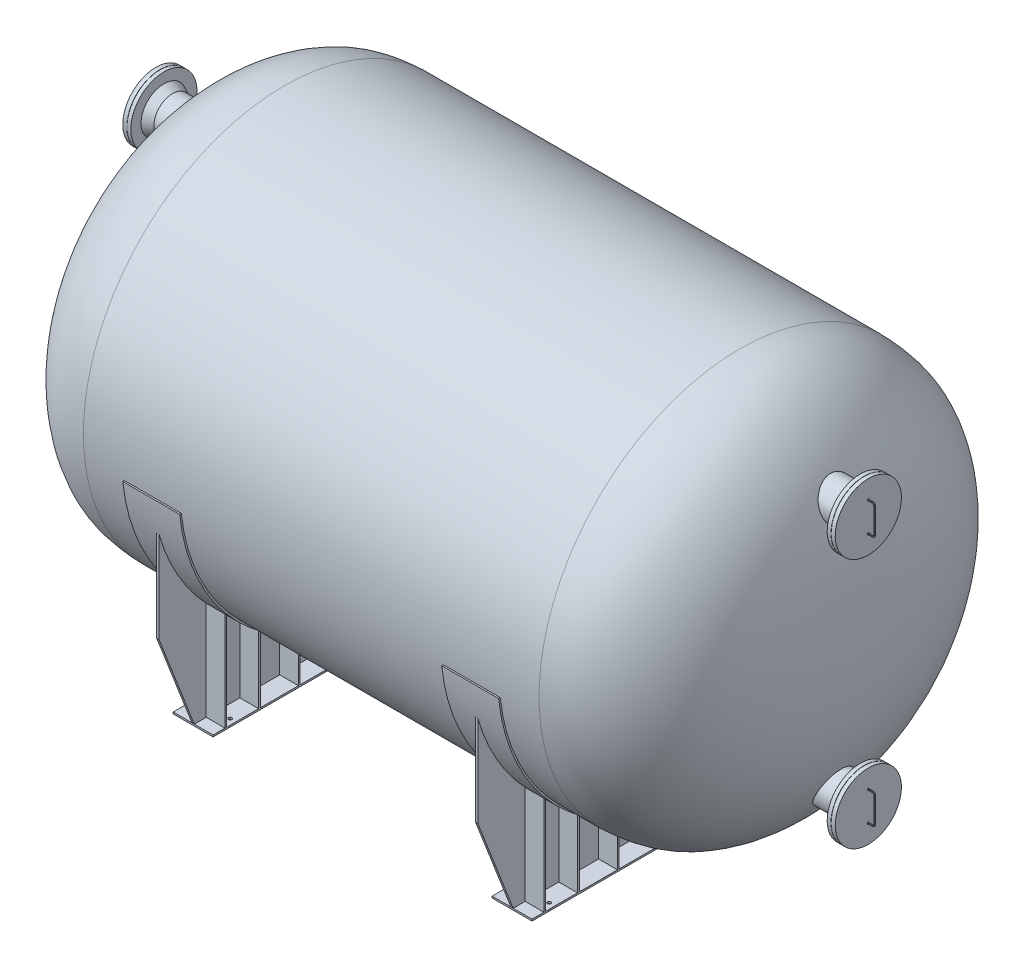
from build123d import *

# Parameters (mm, degrees)
EXTRUDE1_DEPTH         = 250
EXTRUDE2_DEPTH         = 10
SKETCH5_W              = 2800
SKETCH5_H              = 15
EXTRUDE3_DEPTH         = 175
CUT_EXTRUDE5_REACH     = 5203.656
SKETCH6_R              = 15
EXTRUDE4_REACH         = 5203.656
EXTRUDE4_END_RADIUS    = 1778
SKETCH7_W              = 350
SKETCH7_H              = 15
EXTRUDE5_DEPTH         = 5
FILLET1_R              = 4
LPATTERN1_COUNT        = 2
LPATTERN1_PITCH        = 2200
FILLET1_OF_LPATTERN1_R = 4
FILLET1_OF_MIRROR2_R   = 4


with BuildPart() as part:
    # Sketch1 → Revolve1 (revolve)
    with BuildSketch(Plane.XY, mode=Mode.PRIVATE) as revolve1_sk:
        with BuildLine():
            Line((-2000, 1764), (2000, 1764))
            add(Edge.make_bspline(
                [(2000, 1764), (2071.709539433, 1759.493968007), (2357.150579509, 1741.557631102), (2970.826476493, 1179.666295908), (3000, 479.303557809), (3000, 0)],
                knots=[0, 0, 0, 0, 0.095847472, 0.381522491, 1, 1, 1, 1], degree=3))
            Line((3000, 0), (2986, 0))
            add(Edge.make_bspline(
                [(1999.560570727, 1750), (2005.398290599, 1749.633169332), (2017.083149597, 1748.89856732), (2040.373835374, 1747.378548096), (2069.359667097, 1745.280431746), (2103.838488807, 1742.129980196), (2137.930085641, 1738.034970327), (2171.553082303, 1732.684389), (2204.610143011, 1725.784518905), (2237.085978001, 1716.994696117), (2279.768124066, 1702.771267992), (2331.827479031, 1680.545221567), (2392.066003425, 1647.412752748), (2449.861973025, 1608.501331842), (2523.390343256, 1549.835236492), (2591.198281392, 1482.390834705), (2652.454750138, 1409.019703405), (2694.928024022, 1351.732249744), (2733.697895592, 1292.966986748), (2780.595606805, 1212.887273823), (2830.706718203, 1109.632476341), (2878.597366604, 981.195868818), (2927.961071738, 804.582840226), (2958.31560332, 620.985101088), (2975.137741765, 432.605018221), (2982.367162328, 289.493112765), (2985.055177742, 169.172626093), (2985.898218422, 72.572791407), (2986, 24.183563804), (2986, 0)],
                knots=[0.000195399, 0.000195399, 0.000195399, 0.000195399, 0.008006373, 0.015817346, 0.031439293, 0.04706124, 0.062683187, 0.078305134, 0.09392708, 0.109549027, 0.125170974, 0.156414868, 0.187658762, 0.218902656, 0.250146549, 0.312634337, 0.343878231, 0.375122124, 0.406366018, 0.437609912, 0.5000977, 0.562585487, 0.625073275, 0.75004885, 0.812536637, 0.875024425, 0.937512212, 0.968756106, 1, 1, 1, 1], degree=3))
            Line((1999.560570727, 1750), (-1999.560570727, 1750))
            add(Edge.make_bspline(
                [(-2986, 0), (-2986, 24.183563804), (-2985.898218422, 72.572791407), (-2985.055177742, 169.172626093), (-2982.367162328, 289.493112765), (-2975.137741765, 432.605018221), (-2958.31560332, 620.985101088), (-2927.961071738, 804.582840226), (-2878.597366604, 981.195868818), (-2830.706718203, 1109.632476341), (-2780.595606805, 1212.887273823), (-2733.697895592, 1292.966986748), (-2694.928024022, 1351.732249744), (-2652.454750138, 1409.019703405), (-2591.198281392, 1482.390834705), (-2523.390343256, 1549.835236492), (-2449.861973025, 1608.501331842), (-2392.066003425, 1647.412752748), (-2331.827479031, 1680.545221567), (-2279.768124066, 1702.771267992), (-2237.085978001, 1716.994696117), (-2204.610143011, 1725.784518905), (-2171.553082303, 1732.684389), (-2137.930085641, 1738.034970327), (-2103.838488807, 1742.129980196), (-2069.359667097, 1745.280431746), (-2040.373835374, 1747.378548096), (-2017.083149597, 1748.89856732), (-2005.398290599, 1749.633169332), (-1999.560570727, 1750)],
                knots=[0.000195399, 0.000195399, 0.000195399, 0.000195399, 0.031439293, 0.062683187, 0.125170974, 0.187658762, 0.250146549, 0.375122124, 0.437609912, 0.5000977, 0.562585487, 0.593829381, 0.625073275, 0.656317168, 0.687561062, 0.75004885, 0.781292744, 0.812536637, 0.843780531, 0.875024425, 0.890646372, 0.906268319, 0.921890266, 0.937512212, 0.953134159, 0.968756106, 0.984378053, 0.992189027, 1, 1, 1, 1], degree=3))
            Line((-2986, 0), (-3000, 0))
            add(Edge.make_bspline(
                [(-2000, 1764), (-2071.709539433, 1759.493968007), (-2357.150579509, 1741.557631102), (-2970.826476493, 1179.666295908), (-3000, 479.303557809), (-3000, 0)],
                knots=[0, 0, 0, 0, 0.095847472, 0.381522491, 1, 1, 1, 1], degree=3))
        make_face()
    revolve(revolve1_sk.sketch.rotate(Axis((-3000, 0, 0), (1, 0, 0)), 180), axis=Axis((-3000, 0, 0), (1, 0, 0)))

    # Sketch2 → Extrude1 (add, symmetric)
    with BuildSketch(Plane(origin=(-1400, 0, 0), x_dir=(0, 0, -1), z_dir=(1, 0, 0))):
        with BuildLine():
            Line((1754.179437299, -185.877652658), (1768.257192334, -185.877652658))
            ThreePointArc((1768.257192334, -185.877652658), (0, -1778), (-1768.257192334, -185.877652658))
            Line((-1768.257192334, -185.877652658), (-1754.179437299, -185.877652658))
            ThreePointArc((-1754.179437299, -185.877652658), (0, -1764), (1754.179437299, -185.877652658))
        make_face()
    extrude1 = extrude(amount=EXTRUDE1_DEPTH, both=True)

    # Sketch3 → Extrude2 (add, symmetric)
    with BuildSketch(Plane(origin=(-1400, 0, 0), x_dir=(0, 0, -1), z_dir=(1, 0, 0))):
        with BuildLine():
            Line((1710.25640003, -486.114231592), (1710.25640003, -1286.114231592))
            Line((1710.25640003, -1286.114231592), (1400, -2085))
            Line((1400, -2085), (-1400, -2085))
            Line((-1400, -2085), (-1710.25640003, -1286.114231592))
            Line((-1710.25640003, -1286.114231592), (-1710.25640003, -486.114231592))
            ThreePointArc((-1710.25640003, -486.114231592), (0, -1778), (1710.25640003, -486.114231592))
        make_face()
    extrude2 = extrude(amount=EXTRUDE2_DEPTH, both=True)

    # Sketch5 → Extrude3 (add, symmetric)
    with BuildSketch(Plane(origin=(-1400, 0, 0), x_dir=(0, 0, -1), z_dir=(1, 0, 0))):
        with Locations((0, -2092.5)):
            Rectangle(SKETCH5_W, SKETCH5_H)
    extrude3 = extrude(amount=EXTRUDE3_DEPTH, both=True)

    # Sketch6 → Cut-Extrude5 (cut, up to next)
    with BuildSketch(Plane.XZ.offset(2100), mode=Mode.PRIVATE) as cut_extrude5_sk1:
        with Locations(Location((-1525, 1200, 0), (0, 0, 270))):
            Circle(SKETCH6_R)
    cut_extrude5_tool1 = extrude(cut_extrude5_sk1.sketch, amount=-CUT_EXTRUDE5_REACH, mode=Mode.PRIVATE) & part.part
    # Sketch6 → Cut-Extrude5 (cut, up to next)
    with BuildSketch(Plane.XZ.offset(2100), mode=Mode.PRIVATE) as cut_extrude5_sk2:
        with Locations(Location((-1525, -1200, 0), (0, 0, 90))):
            Circle(SKETCH6_R)
    cut_extrude5_tool2 = extrude(cut_extrude5_sk2.sketch, amount=-CUT_EXTRUDE5_REACH, mode=Mode.PRIVATE) & part.part
    # Sketch6 → Cut-Extrude5 (cut, up to next)
    with BuildSketch(Plane.XZ.offset(2100), mode=Mode.PRIVATE) as cut_extrude5_sk3:
        with Locations(Location((-1275, 1200, 0), (0, 0, 90))):
            Circle(SKETCH6_R)
    cut_extrude5_tool3 = extrude(cut_extrude5_sk3.sketch, amount=-CUT_EXTRUDE5_REACH, mode=Mode.PRIVATE) & part.part
    # Sketch6 → Cut-Extrude5 (cut, up to next)
    with BuildSketch(Plane.XZ.offset(2100), mode=Mode.PRIVATE) as cut_extrude5_sk4:
        with Locations(Location((-1275, -1200, 0), (0, 0, 270))):
            Circle(SKETCH6_R)
    cut_extrude5_tool4 = extrude(cut_extrude5_sk4.sketch, amount=-CUT_EXTRUDE5_REACH, mode=Mode.PRIVATE) & part.part
    cut_extrude5_1 = cut_extrude5_tool1.solids().sort_by_distance((-1525, -2100, 1200))[0]
    add(cut_extrude5_1, mode=Mode.SUBTRACT)
    cut_extrude5_2 = cut_extrude5_tool2.solids().sort_by_distance((-1525, -2100, -1200))[0]
    add(cut_extrude5_2, mode=Mode.SUBTRACT)
    cut_extrude5_3 = cut_extrude5_tool3.solids().sort_by_distance((-1275, -2100, 1200))[0]
    add(cut_extrude5_3, mode=Mode.SUBTRACT)
    cut_extrude5_4 = cut_extrude5_tool4.solids().sort_by_distance((-1275, -2100, -1200))[0]
    add(cut_extrude5_4, mode=Mode.SUBTRACT)
    cut_extrude5 = cut_extrude5_1 + cut_extrude5_2 + cut_extrude5_3 + cut_extrude5_4  # Cut-Extrude5 as one shape, for the pattern or mirror that repeats it

    # Extrude4: up to this cylinder (the profile starts outside it)
    extrude4_end = Plane(origin=(-1400, 0, 0), z_dir=(1, 0, 0)) * Cylinder(EXTRUDE4_END_RADIUS, 13964.312, mode=Mode.PRIVATE)
    # Sketch7 → Extrude4 (add, up to the surface)
    with BuildSketch(Plane.XZ.offset(2100), mode=Mode.PRIVATE) as extrude4_sk1:
        with Locations((-1400, 1287.5)):
            Rectangle(SKETCH7_W, SKETCH7_H)
    extrude4_tool1 = extrude(extrude4_sk1.sketch, amount=-EXTRUDE4_REACH, mode=Mode.PRIVATE) - extrude4_end
    # Sketch7 → Extrude4 (add, up to the surface)
    with BuildSketch(Plane.XZ.offset(2100), mode=Mode.PRIVATE) as extrude4_sk2:
        with Locations((-1400, -992.5)):
            Rectangle(SKETCH7_W, SKETCH7_H)
    extrude4_tool2 = extrude(extrude4_sk2.sketch, amount=-EXTRUDE4_REACH, mode=Mode.PRIVATE) - extrude4_end
    # Sketch7 → Extrude4 (add, up to the surface)
    with BuildSketch(Plane.XZ.offset(2100), mode=Mode.PRIVATE) as extrude4_sk3:
        with Locations((-1400, 992.5)):
            Rectangle(SKETCH7_W, SKETCH7_H)
    extrude4_tool3 = extrude(extrude4_sk3.sketch, amount=-EXTRUDE4_REACH, mode=Mode.PRIVATE) - extrude4_end
    # Sketch7 → Extrude4 (add, up to the surface)
    with BuildSketch(Plane.XZ.offset(2100), mode=Mode.PRIVATE) as extrude4_sk4:
        with Locations((-1400, -1287.5)):
            Rectangle(SKETCH7_W, SKETCH7_H)
    extrude4_tool4 = extrude(extrude4_sk4.sketch, amount=-EXTRUDE4_REACH, mode=Mode.PRIVATE) - extrude4_end
    # Sketch7 → Extrude4 (add, up to the surface)
    with BuildSketch(Plane.XZ.offset(2100), mode=Mode.PRIVATE) as extrude4_sk5:
        with Locations((-1400, -292.5)):
            Rectangle(SKETCH7_W, SKETCH7_H)
    extrude4_tool5 = extrude(extrude4_sk5.sketch, amount=-EXTRUDE4_REACH, mode=Mode.PRIVATE) - extrude4_end
    # Sketch7 → Extrude4 (add, up to the surface)
    with BuildSketch(Plane.XZ.offset(2100), mode=Mode.PRIVATE) as extrude4_sk6:
        with Locations((-1400, 642.5)):
            Rectangle(SKETCH7_W, SKETCH7_H)
    extrude4_tool6 = extrude(extrude4_sk6.sketch, amount=-EXTRUDE4_REACH, mode=Mode.PRIVATE) - extrude4_end
    # Sketch7 → Extrude4 (add, up to the surface)
    with BuildSketch(Plane.XZ.offset(2100), mode=Mode.PRIVATE) as extrude4_sk7:
        with Locations((-1400, 292.5)):
            Rectangle(SKETCH7_W, SKETCH7_H)
    extrude4_tool7 = extrude(extrude4_sk7.sketch, amount=-EXTRUDE4_REACH, mode=Mode.PRIVATE) - extrude4_end
    # Sketch7 → Extrude4 (add, up to the surface)
    with BuildSketch(Plane.XZ.offset(2100), mode=Mode.PRIVATE) as extrude4_sk8:
        with Locations((-1400, -642.5)):
            Rectangle(SKETCH7_W, SKETCH7_H)
    extrude4_tool8 = extrude(extrude4_sk8.sketch, amount=-EXTRUDE4_REACH, mode=Mode.PRIVATE) - extrude4_end
    extrude4 = extrude4_tool1.solids().sort_by_distance((-1400, -2100, 1287.5))[0] + extrude4_tool2.solids().sort_by_distance((-1400, -2100, -992.5))[0] + extrude4_tool3.solids().sort_by_distance((-1400, -2100, 992.5))[0] + extrude4_tool4.solids().sort_by_distance((-1400, -2100, -1287.5))[0] + extrude4_tool5.solids().sort_by_distance((-1400, -2100, -292.5))[0] + extrude4_tool6.solids().sort_by_distance((-1400, -2100, 642.5))[0] + extrude4_tool7.solids().sort_by_distance((-1400, -2100, 292.5))[0] + extrude4_tool8.solids().sort_by_distance((-1400, -2100, -642.5))[0]
    add(extrude4)

    # Mirror1: Extrude1, Extrude2, Extrude3, Cut-Extrude5, Extrude4 across plane
    add(extrude1.mirror(Plane(origin=(0, 0, 0), x_dir=(0, 0, 1), z_dir=(1, 0, 0))))
    add(extrude2.mirror(Plane(origin=(0, 0, 0), x_dir=(0, 0, 1), z_dir=(1, 0, 0))))
    add(extrude3.mirror(Plane(origin=(0, 0, 0), x_dir=(0, 0, 1), z_dir=(1, 0, 0))))
    add(cut_extrude5.mirror(Plane(origin=(0, 0, 0), x_dir=(0, 0, 1), z_dir=(1, 0, 0))), mode=Mode.SUBTRACT)
    add(extrude4.mirror(Plane(origin=(0, 0, 0), x_dir=(0, 0, 1), z_dir=(1, 0, 0))))

    # Sketch8 → Revolve2 (revolve)
    with BuildSketch(Plane.XY):
        Polygon((2727.5, 1213.4), (2981.5, 1213.4), (3057, 1250.531112626), (3057, 1340.65), (3090, 1340.65), (3090, 1202.4), (3092, 1202.4), (3092, 1340.65), (3127.5, 1340.65), (3127.5, 1201.4), (3127.5, 1050), (3092, 1050), (3092, 1201.4), (2727.5, 1201.4), align=None)
    revolve2 = revolve(axis=Axis((3212.88421344, 1050, 0), (-1, 0, 0)))

    # Sketch9 → Extrude5 (add, symmetric)
    with BuildSketch(Plane.XY):
        with BuildLine():
            Line((3127.5, 1183.768683462), (3164.255678869, 1183.768683462))
            ThreePointArc((3164.255678869, 1183.768683462), (3181.933348399, 1176.446352992), (3189.255678869, 1158.768683462))
            Line((3189.255678869, 1158.768683462), (3189.255678869, 1050))
            Line((3189.255678869, 1050), (3189.255678869, 941.231316538))
            ThreePointArc((3189.255678869, 941.231316538), (3181.933348399, 923.553647008), (3164.255678869, 916.231316538))
            Line((3164.255678869, 916.231316538), (3127.5, 916.231316538))
            Line((3127.5, 916.231316538), (3127.5, 926.231316538))
            Line((3127.5, 926.231316538), (3164.255678869, 926.231316538))
            ThreePointArc((3164.255678869, 926.231316538), (3174.862280587, 930.62471482), (3179.255678869, 941.231316538))
            Line((3179.255678869, 941.231316538), (3179.255678869, 1050))
            Line((3179.255678869, 1050), (3179.255678869, 1158.768683462))
            ThreePointArc((3179.255678869, 1158.768683462), (3174.862280587, 1169.37528518), (3164.255678869, 1173.768683462))
            Line((3164.255678869, 1173.768683462), (3127.5, 1173.768683462))
            Line((3127.5, 1173.768683462), (3127.5, 1183.768683462))
        make_face()
    extrude5 = extrude(amount=EXTRUDE5_DEPTH, both=True)

    # Fillet1
    fillet1_edges = [part.edges().sort_by_distance(p)[0] for p in [
        (3127.5, 1173.768683462, 0),
        (3127.5, 1178.768683462, -5),
        (3127.5, 1183.768683462, 0),
        (3145.877839435, 1183.768683462, -5),
        (3181.933348399, 1176.446352992, -5),
        (3189.255678869, 1050, -5),
        (3181.933348399, 923.553647008, -5),
        (3145.877839435, 916.231316538, -5),
        (3127.5, 916.231316538, 0),
        (3127.5, 921.231316538, -5),
        (3127.5, 926.231316538, 0),
        (3145.877839435, 926.231316538, -5),
        (3174.862280587, 930.62471482, -5),
        (3179.255678869, 1050, -5),
        (3174.862280587, 1169.37528518, -5),
        (3145.877839435, 1173.768683462, -5),
        (3127.5, 1178.768683462, 5),
        (3145.877839435, 1173.768683462, 5),
        (3174.862280587, 1169.37528518, 5),
        (3179.255678869, 1050, 5),
        (3174.862280587, 930.62471482, 5),
        (3145.877839435, 926.231316538, 5),
        (3127.5, 921.231316538, 5),
        (3145.877839435, 916.231316538, 5),
        (3181.933348399, 923.553647008, 5),
        (3189.255678869, 1050, 5),
        (3181.933348399, 1176.446352992, 5),
        (3145.877839435, 1183.768683462, 5),
    ]]
    fillet(fillet1_edges, radius=FILLET1_R)

    # LPattern1: Revolve2, Extrude5 ×2
    with Locations(*[(0, -i * LPATTERN1_PITCH, 0) for i in range(1, LPATTERN1_COUNT)]):
        add(revolve2)
        add(extrude5)

    # Fillet1 of LPattern1
    fillet1_of_lpattern1_edges = [part.edges().sort_by_distance(p)[0] for p in [
        (3127.5, -1026.231316538, 0),
        (3127.5, -1021.231316538, -5),
        (3127.5, -1016.231316538, 0),
        (3145.877839435, -1016.231316538, -5),
        (3181.933348399, -1023.553647008, -5),
        (3189.255678869, -1150, -5),
        (3181.933348399, -1276.446352992, -5),
        (3145.877839435, -1283.768683462, -5),
        (3127.5, -1283.768683462, 0),
        (3127.5, -1278.768683462, -5),
        (3127.5, -1273.768683462, 0),
        (3145.877839435, -1273.768683462, -5),
        (3174.862280587, -1269.37528518, -5),
        (3179.255678869, -1150, -5),
        (3174.862280587, -1030.62471482, -5),
        (3145.877839435, -1026.231316538, -5),
        (3127.5, -1021.231316538, 5),
        (3145.877839435, -1026.231316538, 5),
        (3174.862280587, -1030.62471482, 5),
        (3179.255678869, -1150, 5),
        (3174.862280587, -1269.37528518, 5),
        (3145.877839435, -1273.768683462, 5),
        (3127.5, -1278.768683462, 5),
        (3145.877839435, -1283.768683462, 5),
        (3181.933348399, -1276.446352992, 5),
        (3189.255678869, -1150, 5),
        (3181.933348399, -1023.553647008, 5),
        (3145.877839435, -1016.231316538, 5),
    ]]
    fillet(fillet1_of_lpattern1_edges, radius=FILLET1_OF_LPATTERN1_R)

    # Mirror2: Revolve2, Extrude5 across plane
    add(revolve2.mirror(Plane(origin=(0, 0, 0), x_dir=(0, 0, 1), z_dir=(1, 0, 0))))
    add(extrude5.mirror(Plane(origin=(0, 0, 0), x_dir=(0, 0, 1), z_dir=(1, 0, 0))))

    # Fillet1 of Mirror2
    fillet1_of_mirror2_edges = [part.edges().sort_by_distance(p)[0] for p in [
        (-3127.5, 1173.768683462, 0),
        (-3127.5, 1178.768683462, -5),
        (-3127.5, 1183.768683462, 0),
        (-3145.877839435, 1183.768683462, -5),
        (-3181.933348399, 1176.446352992, -5),
        (-3189.255678869, 1050, -5),
        (-3181.933348399, 923.553647008, -5),
        (-3145.877839435, 916.231316538, -5),
        (-3127.5, 916.231316538, 0),
        (-3127.5, 921.231316538, -5),
        (-3127.5, 926.231316538, 0),
        (-3145.877839435, 926.231316538, -5),
        (-3174.862280587, 930.62471482, -5),
        (-3179.255678869, 1050, -5),
        (-3174.862280587, 1169.37528518, -5),
        (-3145.877839435, 1173.768683462, -5),
        (-3127.5, 1178.768683462, 5),
        (-3145.877839435, 1173.768683462, 5),
        (-3174.862280587, 1169.37528518, 5),
        (-3179.255678869, 1050, 5),
        (-3174.862280587, 930.62471482, 5),
        (-3145.877839435, 926.231316538, 5),
        (-3127.5, 921.231316538, 5),
        (-3145.877839435, 916.231316538, 5),
        (-3181.933348399, 923.553647008, 5),
        (-3189.255678869, 1050, 5),
        (-3181.933348399, 1176.446352992, 5),
        (-3145.877839435, 1183.768683462, 5),
    ]]
    fillet(fillet1_of_mirror2_edges, radius=FILLET1_OF_MIRROR2_R)


solid = part.part
